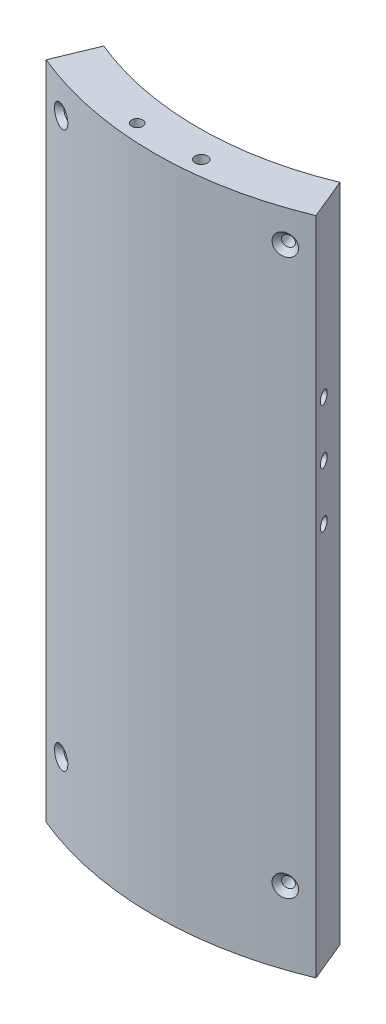
from build123d import *

# Parameters (mm, degrees)
SKETCH1_W                       = 46.2
SKETCH1_H                       = 27.3
BOSS_EXTRUDE1_DEPTH             = 107
CUT_EXTRUDE1_DEPTH              = 24
CUT_EXTRUDE2_DEPTH              = 19.2
CUT_EXTRUDE3_DEPTH              = 50
CUT_EXTRUDE4_DEPTH              = 1
SKETCH6_W                       = 24.8
SKETCH6_H                       = 1.7
CUT_EXTRUDE5_DEPTH              = 5.48
FILLET1_R                       = 3.1
SKETCH7_W                       = 27.3
SKETCH7_H                       = 107
BOSS_EXTRUDE2_DEPTH             = 35.75
SKETCH8_W                       = 27.3
SKETCH8_H                       = 107
BOSS_EXTRUDE3_DEPTH             = 35.75
SKETCH9_W                       = 117.7
SKETCH9_H                       = 107
BOSS_EXTRUDE4_DEPTH             = 39.2125
SKETCH10_OUTSIDE_W              = 154.182
SKETCH10_OUTSIDE_H              = 102.994
CUT_EXTRUDE6_DEPTH              = 107
SKETCH14_R                      = 1
SKETCH15_R                      = 1
SKETCH15_R_2                    = 0.9
CUT_EXTRUDE7_DEPTH              = 50
F_2_64_TAPPED_HOLE1_D           = 1.778
F_2_64_TAPPED_HOLE1_DEPTH       = 19.479603582
F_2_64_TAPPED_HOLE1_CSINK_D     = 3.4544
F_2_64_TAPPED_HOLE1_CSINK_ANGLE = 90
CIRPATTERN1_COUNT               = 2
CIRPATTERN1_ANGLE               = 37
LPATTERN1_COUNT                 = 2
LPATTERN1_PITCH                 = 90
LPATTERN1_COPY_1_D              = 1.778
LPATTERN1_COPY_1_DEPTH          = 19.479603582
LPATTERN1_COPY_1_CSINK_D        = 3.4544
LPATTERN1_COPY_1_CSINK_ANGLE    = 90
SKETCH25_R                      = 1.15
CUT_EXTRUDE8_DEPTH              = 4.6
CUT_EXTRUDE8_DIRECTION_2_REACH  = 6.619
CUT_EXTRUDE10_START             = -1
SKETCH26_R                      = 1.75
CUT_EXTRUDE10_DEPTH             = 2


with BuildPart() as part:
    # Sketch1 → Boss-Extrude1 (new body)
    with BuildSketch(Plane(origin=(0, 0, 0), x_dir=(1, 0, 0), z_dir=(0, 1, 0))):
        Rectangle(SKETCH1_W, SKETCH1_H)
    extrude(amount=BOSS_EXTRUDE1_DEPTH)

    # Sketch2 → Cut-Extrude1 (cut)
    with BuildSketch(Plane.XZ):
        Polygon((-5.5, 3.65), (4.8, 3.65), (4.8, 3.05), (10.4, 3.05), (10.4, 0.45), (11.7, 0.45), (11.7, -2.15), (13.1, -2.15), (13.1, -3.65), (-4.4, -3.65), (-4.4, -2.25), (-13.1, -2.25), (-13.1, 1.25), (-5.5, 1.25), align=None)
    extrude(amount=-CUT_EXTRUDE1_DEPTH, mode=Mode.SUBTRACT)

    # Sketch3 → Cut-Extrude2 (cut)
    with BuildSketch(Plane.XZ.offset(-24)):
        Polygon((-13.1, 1.25), (-13.1, -2.25), (-4.4, -2.25), (-4.4, -3.65), (13.1, -3.65), (13.1, -2.15), (11.7, -2.15), (11.7, 0.45), (10.4, 0.45), (10.4, 2.15), (4.8, 2.15), (4.8, 3.65), (-5.5, 3.65), (-5.5, 1.25), align=None)
    extrude(amount=-CUT_EXTRUDE2_DEPTH, mode=Mode.SUBTRACT)

    # Sketch4 → Cut-Extrude3 (cut)
    with BuildSketch(Plane.XZ.offset(-43.2)):
        Polygon((-13.1, -2.25), (11.7, -2.25), (11.7, -0.55), (8.9, -0.55), (8.9, 1.15), (4.8, 1.15), (4.8, 3.65), (-5.5, 3.65), (-5.5, 1.25), (-9.3, 1.25), (-9.3, -0.55), (-13.1, -0.55), align=None)
    extrude(amount=-CUT_EXTRUDE3_DEPTH, mode=Mode.SUBTRACT)

    # Sketch5 → Cut-Extrude4 (cut)
    with BuildSketch(Plane.XZ.offset(-93.2)):
        Polygon((-13.1, -2.25), (11.7, -2.25), (11.7, -0.55), (4.8, -0.55), (4.8, 3.65), (-5.5, 3.65), (-5.5, -0.55), (-13.1, -0.55), align=None)
    extrude(amount=-CUT_EXTRUDE4_DEPTH, mode=Mode.SUBTRACT)

    # Sketch6 → Cut-Extrude5 (cut)
    with BuildSketch(Plane.XZ.offset(-94.2)):
        with Locations((-0.7, -1.4)):
            Rectangle(SKETCH6_W, SKETCH6_H)
    extrude(amount=-CUT_EXTRUDE5_DEPTH, mode=Mode.SUBTRACT)

    # Fillet1
    fillet1_edges = [part.edges().sort_by_distance(p)[0] for p in [
        (-13.1, 99.68, -1.4),
        (11.7, 99.68, -1.4),
    ]]
    fillet(fillet1_edges, radius=FILLET1_R)

    # Sketch7 → Boss-Extrude2 (add)
    with BuildSketch(Plane.ZY.offset(23.1)):
        with Locations((0, 53.5)):
            Rectangle(SKETCH7_W, SKETCH7_H)
    extrude(amount=BOSS_EXTRUDE2_DEPTH)

    # Sketch8 → Boss-Extrude3 (add)
    with BuildSketch(Plane(origin=(23.1, 0, 0), x_dir=(0, 0, -1), z_dir=(1, 0, 0))):
        with Locations((0, 53.5)):
            Rectangle(SKETCH8_W, SKETCH8_H)
    extrude(amount=BOSS_EXTRUDE3_DEPTH)

    # Sketch9 → Boss-Extrude4 (add)
    with BuildSketch(Plane(origin=(0, 0, -13.65), x_dir=(-1, 0, 0), z_dir=(0, 0, -1))):
        with Locations((0, 53.5)):
            Rectangle(SKETCH9_W, SKETCH9_H)
    extrude(amount=BOSS_EXTRUDE4_DEPTH)

    # Sketch10 outside → Cut-Extrude6 (cut)
    with BuildSketch(Plane.XZ):
        with Locations((0, -19.606)):
            Rectangle(SKETCH10_OUTSIDE_W, SKETCH10_OUTSIDE_H)
        with BuildLine():
            Line((-19.034171618, -6.868523374), (-21.77035816, -0.262784717))
            ThreePointArc((-21.77035816, -0.262784717), (0.1, 4.0875), (21.97035816, -0.262784717))
            Line((21.97035816, -0.262784717), (19.234171618, -6.868523374))
            ThreePointArc((19.234171618, -6.868523374), (0.1, -3.0625), (-19.034171618, -6.868523374))
        make_face(mode=Mode.SUBTRACT)
    extrude(amount=-CUT_EXTRUDE6_DEPTH, mode=Mode.SUBTRACT)

    # Sketch14 → Cut-Revolve1 (revolve, cut)
    with BuildSketch(Plane(origin=(-18.675071449, 0, -7.735467873), x_dir=(-0.382683432, 0, 0.923879533), z_dir=(-0.923879533, 0, -0.382683432))):
        with Locations((5.750873963, 71.1)):
            Circle(SKETCH14_R)
        with Locations((5.750873963, 62.2)):
            Circle(SKETCH14_R)
        with Locations((5.750873963, 80)):
            Circle(SKETCH14_R)
    revolve(axis=Axis((0.1, 107, -53.0625), (0, -1, 0)), mode=Mode.SUBTRACT)

    # Sketch15 → Cut-Extrude7 (cut)
    with BuildSketch(Plane(origin=(0, 107, 0), x_dir=(1, 0, 0), z_dir=(0, 1, 0))):
        with Locations((4.8, -1.15)):
            Circle(SKETCH15_R)
        with Locations((-5.5, -1.25)):
            Circle(SKETCH15_R_2)
    extrude(amount=-CUT_EXTRUDE7_DEPTH, mode=Mode.SUBTRACT)

    # #2-64 Tapped Hole1
    with Locations(Plane(origin=(-17.928608884, 101.793366011, 1.169333472), x_dir=(0.948938468, 0, 0.315461223), z_dir=(-0.315461223, 0, 0.948938468))):
        with Locations((-1e-09, 0)):
            f_2_64_tapped_hole1 = CounterSinkHole(F_2_64_TAPPED_HOLE1_D / 2, F_2_64_TAPPED_HOLE1_CSINK_D / 2, depth=F_2_64_TAPPED_HOLE1_DEPTH, counter_sink_angle=F_2_64_TAPPED_HOLE1_CSINK_ANGLE)

    # CirPattern1: #2-64 Tapped Hole1 ×2 about axis
    cirpattern1_axis = Axis((0.1, 0, -53.0625), (0, 1, 0))
    for i in range(1, CIRPATTERN1_COUNT):
        add(f_2_64_tapped_hole1.rotate(cirpattern1_axis, i * CIRPATTERN1_ANGLE / (CIRPATTERN1_COUNT - 1)), mode=Mode.SUBTRACT)

    # LPattern1: #2-64 Tapped Hole1 ×2
    with Locations(*[(0, -i * LPATTERN1_PITCH, 0) for i in range(1, LPATTERN1_COUNT)]):
        add(f_2_64_tapped_hole1, mode=Mode.SUBTRACT)

    # LPattern1 copy 1
    with Locations(Plane(origin=(18.339244865, 11.793366011, 1.098855659), x_dir=(0.947705261, 0, -0.319146892), z_dir=(0.319146892, 0, 0.947705261))):
        with Locations((-1e-09, 0)):
            CounterSinkHole(LPATTERN1_COPY_1_D / 2, LPATTERN1_COPY_1_CSINK_D / 2, depth=LPATTERN1_COPY_1_DEPTH, counter_sink_angle=LPATTERN1_COPY_1_CSINK_ANGLE)

    # Sketch25 → Cut-Extrude8 (cut)
    with BuildSketch(Plane.XY.offset(-2.25)):
        with Locations((-9.9075, 95.74)):
            Circle(SKETCH25_R)
        with Locations((8.5075, 95.74)):
            Circle(SKETCH25_R)
        with Locations((-9.9075, 6.84)):
            Circle(SKETCH25_R)
    extrude(amount=CUT_EXTRUDE8_DEPTH, mode=Mode.SUBTRACT)

    # Sketch25 → Cut-Extrude8 direction 2 (cut, up to next)
    with BuildSketch(Plane.XY.offset(-2.25), mode=Mode.PRIVATE) as cut_extrude8_direction_2_sk1:
        with Locations((-9.9075, 95.74)):
            Circle(SKETCH25_R)
    cut_extrude8_direction_2_tool1 = extrude(cut_extrude8_direction_2_sk1.sketch, amount=-CUT_EXTRUDE8_DIRECTION_2_REACH, mode=Mode.PRIVATE) & part.part
    add(cut_extrude8_direction_2_tool1.solids().sort_by_distance((-9.9075, 95.74, -2.25))[0], mode=Mode.SUBTRACT)
    # Sketch25 → Cut-Extrude8 direction 2 (cut, up to next)
    with BuildSketch(Plane.XY.offset(-2.25), mode=Mode.PRIVATE) as cut_extrude8_direction_2_sk2:
        with Locations((8.5075, 95.74)):
            Circle(SKETCH25_R)
    cut_extrude8_direction_2_tool2 = extrude(cut_extrude8_direction_2_sk2.sketch, amount=-CUT_EXTRUDE8_DIRECTION_2_REACH, mode=Mode.PRIVATE) & part.part
    add(cut_extrude8_direction_2_tool2.solids().sort_by_distance((8.5075, 95.74, -2.25))[0], mode=Mode.SUBTRACT)
    # Sketch25 → Cut-Extrude8 direction 2 (cut, up to next)
    with BuildSketch(Plane.XY.offset(-2.25), mode=Mode.PRIVATE) as cut_extrude8_direction_2_sk3:
        with Locations((-9.9075, 6.84)):
            Circle(SKETCH25_R)
    cut_extrude8_direction_2_tool3 = extrude(cut_extrude8_direction_2_sk3.sketch, amount=-CUT_EXTRUDE8_DIRECTION_2_REACH, mode=Mode.PRIVATE) & part.part
    add(cut_extrude8_direction_2_tool3.solids().sort_by_distance((-9.9075, 6.84, -2.25))[0], mode=Mode.SUBTRACT)

    # Sketch26 → Cut-Extrude10 (cut)
    with BuildSketch(Plane.XY.offset(-2.25).offset(CUT_EXTRUDE10_START)):
        with Locations((-9.9075, 95.74)):
            Circle(SKETCH26_R)
        with Locations((8.5075, 95.74)):
            Circle(SKETCH26_R)
        with Locations((-9.9075, 6.84)):
            Circle(SKETCH26_R)
    extrude(amount=-CUT_EXTRUDE10_DEPTH, mode=Mode.SUBTRACT)


solid = part.part
